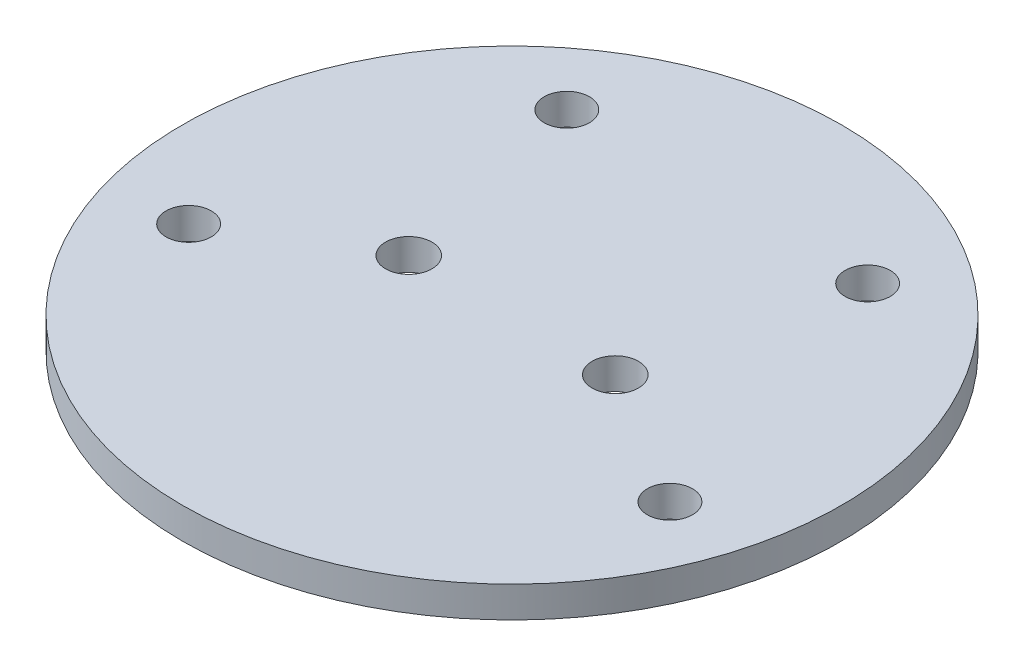
from build123d import *

# Parameters (mm, degrees)
SKETCH1_R           = 50.673
SKETCH1_R_2         = 3.5687
SKETCH1_R_3         = 3.475000035
BOSS_EXTRUDE1_DEPTH = 4.7752


with BuildPart() as part:
    # Sketch1 → Boss-Extrude1 (new body)
    with BuildSketch(Plane(origin=(0, 0, 0), x_dir=(1, 0, 0), z_dir=(0, 1, 0))):
        Circle(SKETCH1_R)
        with Locations((-15.875, 0)):
            Circle(SKETCH1_R_2, mode=Mode.SUBTRACT)
        with Locations((15.875, 0)):
            Circle(SKETCH1_R_2, mode=Mode.SUBTRACT)
        with Locations((-37.000474805, -12.718618741)):
            Circle(SKETCH1_R_3, mode=Mode.SUBTRACT)
        with Locations((-23.12973035, 31.556520284)):
            Circle(SKETCH1_R_3, mode=Mode.SUBTRACT)
        with Locations((23.12973035, 31.556520284)):
            Circle(SKETCH1_R_3, mode=Mode.SUBTRACT)
        with Locations((37.000474805, -12.718618741)):
            Circle(SKETCH1_R_3, mode=Mode.SUBTRACT)
    extrude(amount=BOSS_EXTRUDE1_DEPTH)


solid = part.part
